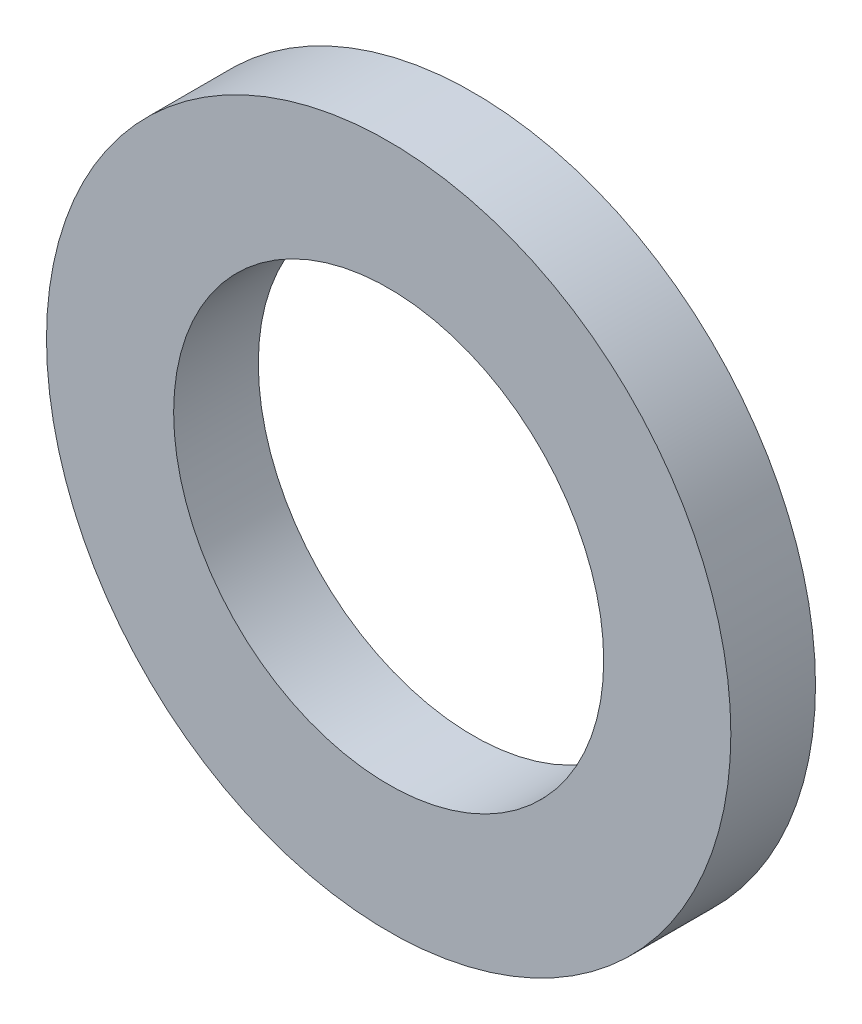
from build123d import *

# Parameters (mm, degrees)
SKETCH1_R           = 6.36499997
SKETCH1_R_2         = 4
BOSS_EXTRUDE1_DEPTH = 1.5748


with BuildPart() as part:
    # Sketch1 → Boss-Extrude1 (new body)
    with BuildSketch(Plane.XY):
        Circle(SKETCH1_R)
        Circle(SKETCH1_R_2, mode=Mode.SUBTRACT)
    extrude(amount=BOSS_EXTRUDE1_DEPTH)


solid = part.part
